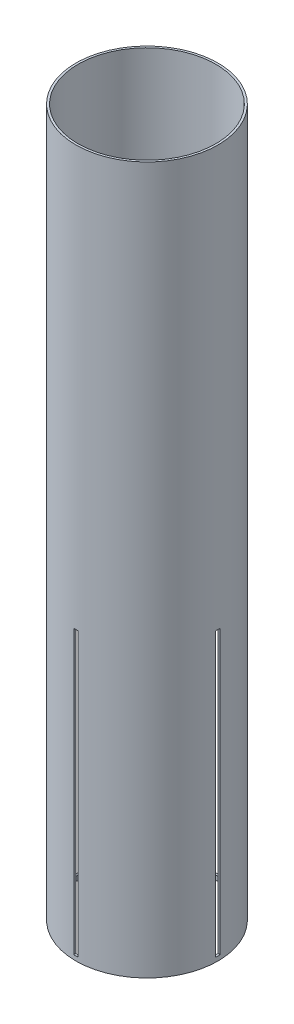
from build123d import *

# Parameters (mm, degrees)
SKETCH1_R           = 51.054
SKETCH1_R_2         = 49.53
BOSS_EXTRUDE1_DEPTH = 508
SKETCH2_W           = 3.175
SKETCH2_H           = 203.2
CUT_EXTRUDE1_DEPTH  = 52.054
CIRPATTERN1_COUNT   = 4


with BuildPart() as part:
    # Sketch1 → Boss-Extrude1 (new body)
    with BuildSketch(Plane(origin=(0, 0, 0), x_dir=(1, 0, 0), z_dir=(0, 1, 0))):
        Circle(SKETCH1_R)
        Circle(SKETCH1_R_2, mode=Mode.SUBTRACT)
    extrude(amount=BOSS_EXTRUDE1_DEPTH)

    # Sketch2 → Cut-Extrude1 (cut, through all)
    with BuildSketch(Plane.XY):
        with Locations((0, 104.775)):
            Rectangle(SKETCH2_W, SKETCH2_H)
    cut_extrude1 = extrude(amount=-CUT_EXTRUDE1_DEPTH, mode=Mode.SUBTRACT)

    # CirPattern1: Cut-Extrude1 ×4 about axis
    cirpattern1_axis = Axis((0, 0, 0), (0, 1, 0))
    for i in range(1, CIRPATTERN1_COUNT):
        add(cut_extrude1.rotate(cirpattern1_axis, i * 360 / CIRPATTERN1_COUNT), mode=Mode.SUBTRACT)


solid = part.part
